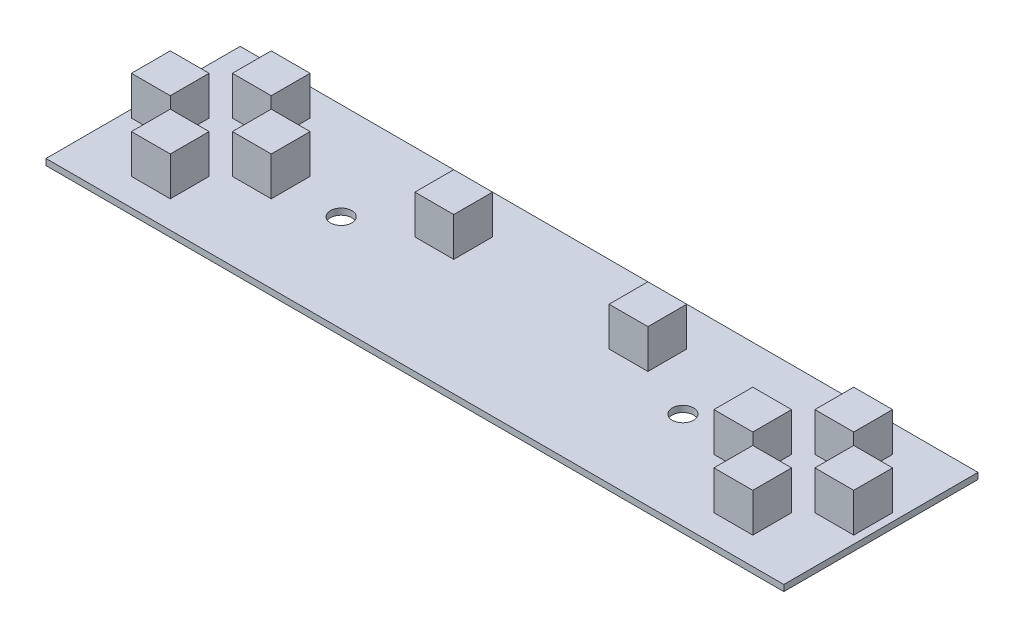
from build123d import *

# Parameters (mm, degrees)
SKETCH1_W            = 190
SKETCH1_H            = 50
BASE_DEPTH           = 0.8
SKETCH2_W            = 10
SKETCH2_H            = 10
SWITCHES_DEPTH       = 10
M5_CLEARANCE_HOLE1_D = 5.5


with BuildPart() as part:
    # Sketch1 → Base (new body, symmetric)
    with BuildSketch(Plane(origin=(0, 0, 0), x_dir=(1, 0, 0), z_dir=(0, 1, 0))):
        Rectangle(SKETCH1_W, SKETCH1_H)
    extrude(amount=BASE_DEPTH, both=True)

    # Sketch2 → Switches (add)
    with BuildSketch(Plane(origin=(0, 0.8, 0), x_dir=(1, 0, 0), z_dir=(0, 1, 0))):
        with Locations((-62, 0)):
            Rectangle(SKETCH2_W, SKETCH2_H)
        with Locations((-75, 13)):
            Rectangle(SKETCH2_W, SKETCH2_H)
        with Locations((-75, -13)):
            Rectangle(SKETCH2_W, SKETCH2_H)
        with Locations((-88, 0)):
            Rectangle(SKETCH2_W, SKETCH2_H)
        with Locations((-25, 10)):
            Rectangle(SKETCH2_W, SKETCH2_H)
        with Locations((25, 10)):
            Rectangle(SKETCH2_W, SKETCH2_H)
        with Locations((88, 0)):
            Rectangle(SKETCH2_W, SKETCH2_H)
        with Locations((75, -13)):
            Rectangle(SKETCH2_W, SKETCH2_H)
        with Locations((62, 0)):
            Rectangle(SKETCH2_W, SKETCH2_H)
        with Locations((75, 13)):
            Rectangle(SKETCH2_W, SKETCH2_H)
    extrude(amount=SWITCHES_DEPTH)

    # M5 Clearance Hole1 (through all)
    with Locations(Plane(origin=(0, 0.8, 0), x_dir=(1, 0, 0), z_dir=(0, 1, 0))):
        with Locations((-44, 0), (44, 0)):
            Hole(M5_CLEARANCE_HOLE1_D / 2)


solid = part.part
